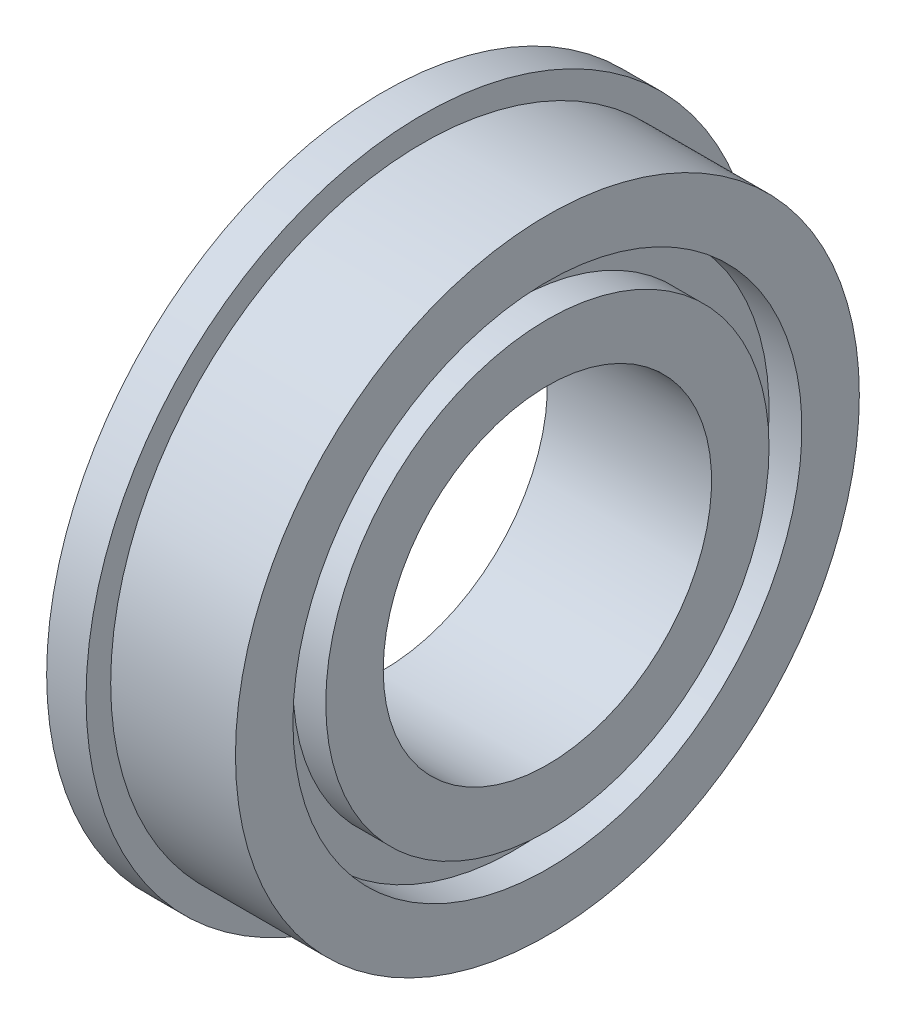
from build123d import *


with BuildPart() as part:
    # Sketch2 → Revolve1 (revolve)
    with BuildSketch(Plane.XY):
        Polygon((-1.2, 10.25), (0, 10.25), (0, 9.5), (3.8, 9.5), (3.8, 7.75), (2.8, 7.75), (2.8, 6.75), (3.8, 6.75), (3.8, 5), (-1.2, 5), (-1.2, 6.75), (-0.2, 6.75), (-0.2, 7.75), (-1.2, 7.75), align=None)
    revolve(axis=Axis((0, 0, 0), (1, 0, 0)))


solid = part.part
